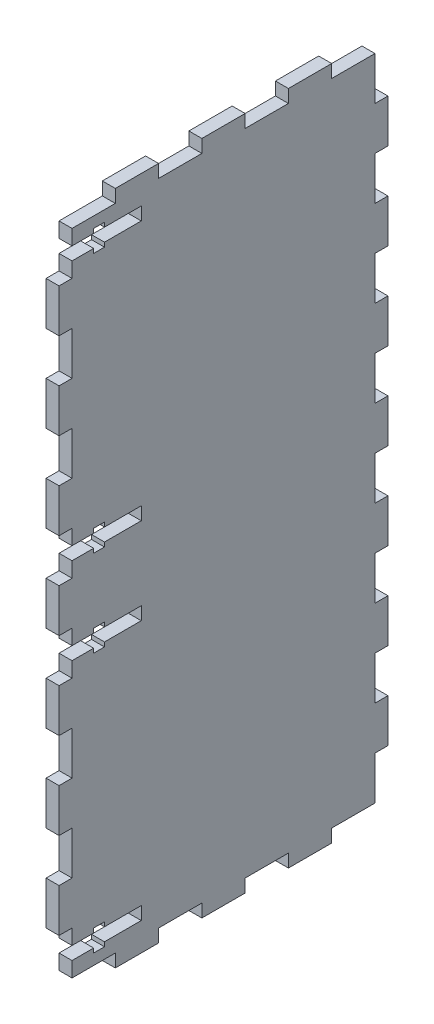
from build123d import *

# Parameters (mm, degrees)
BOSS_EXTRUDE1_DEPTH = 3


with BuildPart() as part:
    # Sketch1 → Boss-Extrude1 (new body)
    with BuildSketch(Plane(origin=(0, 0, 0), x_dir=(0, 0, -1), z_dir=(1, 0, 0))):
        Polygon((10, 153.005875518), (20, 153.005875518), (20, 150.005875518), (30, 150.005875518), (30, 153.005875518), (40, 153.005875518), (40, 150.005875518), (50, 150.005875518), (50, 153.005875518), (60, 153.005875518), (60, 150.005875518), (70, 150.005875518), (70, 146.5), (70, 143.5), (70, 140), (73, 140), (73, 130), (70, 130), (70, 120), (73, 120), (73, 110), (70, 110), (70, 100), (73, 100), (73, 90), (70, 90), (70, 83.5), (70, 80), (73, 80), (73, 70), (70, 70), (70, 66.5), (70, 63.5), (70, 60), (73, 60), (73, 50), (70, 50), (70, 40), (73, 40), (73, 30), (70, 30), (70, 20), (73, 20), (73, 10), (70, 10), (70, 6.5), (70, 3.5), (70, 0), (60, 0), (60, -3), (50, -3), (50, 0), (40, 0), (40, -3), (30, -3), (30, 0), (20, 0), (20, -3), (10, -3), (10, 0), (0, 0), (0, 3.5), (5, 3.5), (5, 2.5), (7.5, 2.5), (7.5, 3.5), (16, 3.5), (16, 6.5), (7.5, 6.5), (7.5, 7.5), (5, 7.5), (5, 6.5), (0, 6.5), (0, 10), (-3, 10), (-3, 20), (0, 20), (0, 30), (-3, 30), (-3, 40), (0, 40), (0, 50), (-3, 50), (-3, 60), (0, 60), (0, 63.5), (5, 63.5), (5, 62.5), (7.5, 62.5), (7.5, 63.5), (16, 63.5), (16, 66.5), (7.5, 66.5), (7.5, 67.5), (5, 67.5), (5, 66.5), (0, 66.5), (0, 70), (-3, 70), (-3, 80), (0, 80), (0, 83.5), (5, 83.5), (5, 82.5), (7.5, 82.5), (7.5, 83.5), (16, 83.5), (16, 86.5), (7.5, 86.5), (7.5, 87.5), (5, 87.5), (5, 86.5), (0, 86.5), (0, 90), (-3, 90), (-3, 100), (0, 100), (0, 110), (-3, 110), (-3, 120), (0, 120), (0, 130), (-3, 130), (-3, 140), (0, 140), (0, 143.5), (5, 143.5), (5, 142.5), (7.5, 142.5), (7.5, 143.5), (16, 143.5), (16, 146.5), (7.5, 146.5), (7.5, 147.5), (5, 147.5), (5, 146.5), (0, 146.5), (0, 150.005875518), (10, 150.005875518), align=None)
    extrude(amount=BOSS_EXTRUDE1_DEPTH)


solid = part.part
